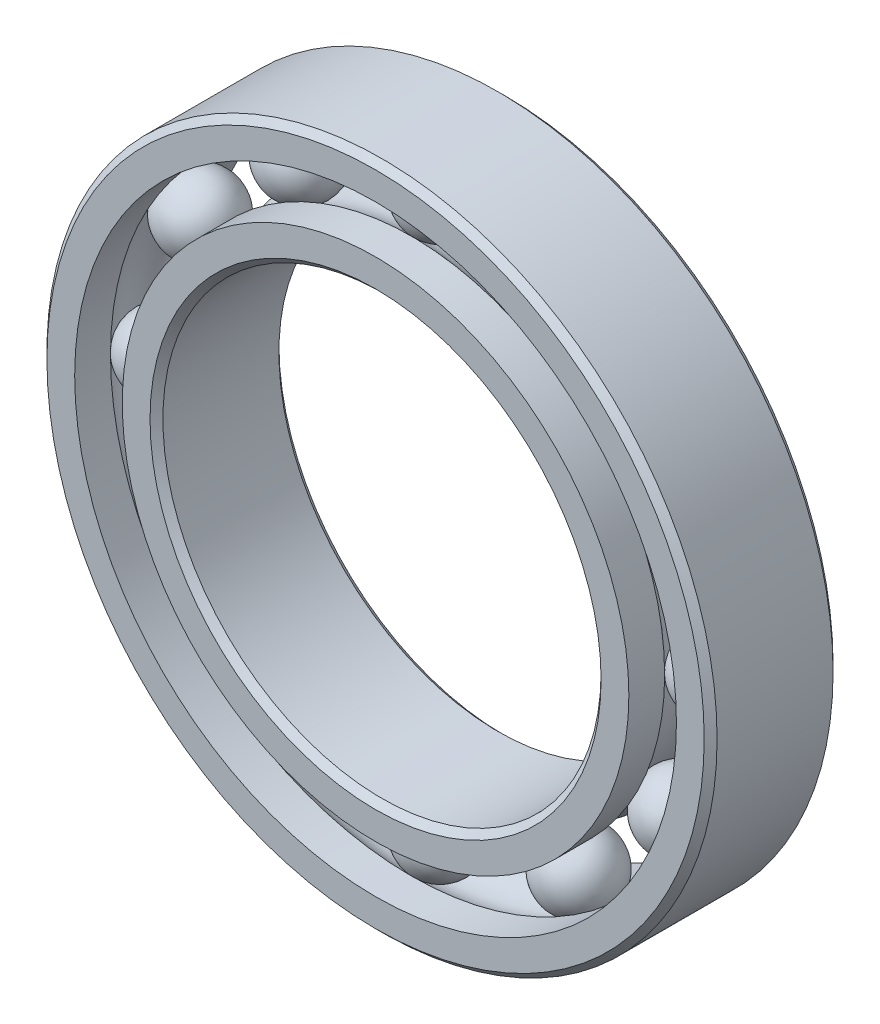
from build123d import *

# Parameters (mm, degrees)
CIRPATTERN1_COUNT = 12


with BuildPart() as part:
    # Sketch1 → Revolve1 (revolve)
    with BuildSketch(Plane(origin=(0, 0, 0), x_dir=(0, 0, -1), z_dir=(1, 0, 0))):
        with BuildLine():
            Line((2.25, 13), (-2.25, 13))
            Line((-2.25, 13), (-2.5, 12.75))
            Line((-2.5, 12.75), (-2.5, 11.673076923))
            Line((-2.5, 11.673076923), (-1.111111111, 11.673076923))
            ThreePointArc((-1.111111111, 11.673076923), (0, 12.194520303), (1.111111111, 11.673076923))
            Line((1.111111111, 11.673076923), (2.5, 11.673076923))
            Line((2.5, 11.673076923), (2.5, 12.75))
            Line((2.5, 12.75), (2.25, 13))
        make_face()
    revolve(axis=Axis((0, 0, 2.5), (0, 0, -1)))


with BuildPart() as body_2:
    # Sketch3 → Revolve3 (revolve)
    with BuildSketch(Plane(origin=(0, 0, 0), x_dir=(0, 0, -1), z_dir=(1, 0, 0))):
        with BuildLine():
            Line((-2.5, 9.826923077), (-1.111111111, 9.826923077))
            ThreePointArc((-1.111111111, 9.826923077), (0, 9.305479697), (1.111111111, 9.826923077))
            Line((1.111111111, 9.826923077), (2.5, 9.826923077))
            Line((2.5, 9.826923077), (2.5, 8.75))
            Line((2.5, 8.75), (2.25, 8.5))
            Line((2.25, 8.5), (-2.25, 8.5))
            Line((-2.25, 8.5), (-2.5, 8.75))
            Line((-2.5, 8.75), (-2.5, 9.826923077))
        make_face()
    revolve(axis=Axis((0, 0, 2.5), (0, 0, -1)))


with BuildPart() as body_3:
    # Sketch4 → Revolve4 (revolve)
    with BuildSketch(Plane(origin=(0, 0, 0), x_dir=(0, 0, -1), z_dir=(1, 0, 0))):
        with BuildLine():
            Line((-1.444520303, 10.75), (1.444520303, 10.75))
            ThreePointArc((1.444520303, 10.75), (0, 12.194520303), (-1.444520303, 10.75))
        make_face()
    revolve(axis=Axis((0, 10.75, 1.444520303), (0, 0, -1)))


with BuildPart() as cirpattern1_1:
    # CirPattern1: pattern copy
    add(body_3.part.rotate(Axis((0, 0, -2.5), (0, 0, 1)), 1 * 360 / CIRPATTERN1_COUNT))


with BuildPart() as cirpattern1_2:
    # CirPattern1: pattern copy
    add(body_3.part.rotate(Axis((0, 0, -2.5), (0, 0, 1)), 2 * 360 / CIRPATTERN1_COUNT))


with BuildPart() as cirpattern1_3:
    # CirPattern1: pattern copy
    add(body_3.part.rotate(Axis((0, 0, -2.5), (0, 0, 1)), 3 * 360 / CIRPATTERN1_COUNT))


with BuildPart() as cirpattern1_4:
    # CirPattern1: pattern copy
    add(body_3.part.rotate(Axis((0, 0, -2.5), (0, 0, 1)), 4 * 360 / CIRPATTERN1_COUNT))


with BuildPart() as cirpattern1_5:
    # CirPattern1: pattern copy
    add(body_3.part.rotate(Axis((0, 0, -2.5), (0, 0, 1)), 5 * 360 / CIRPATTERN1_COUNT))


with BuildPart() as cirpattern1_6:
    # CirPattern1: pattern copy
    add(body_3.part.rotate(Axis((0, 0, -2.5), (0, 0, 1)), 6 * 360 / CIRPATTERN1_COUNT))


with BuildPart() as cirpattern1_7:
    # CirPattern1: pattern copy
    add(body_3.part.rotate(Axis((0, 0, -2.5), (0, 0, 1)), 7 * 360 / CIRPATTERN1_COUNT))


with BuildPart() as cirpattern1_8:
    # CirPattern1: pattern copy
    add(body_3.part.rotate(Axis((0, 0, -2.5), (0, 0, 1)), 8 * 360 / CIRPATTERN1_COUNT))


with BuildPart() as cirpattern1_9:
    # CirPattern1: pattern copy
    add(body_3.part.rotate(Axis((0, 0, -2.5), (0, 0, 1)), 9 * 360 / CIRPATTERN1_COUNT))


with BuildPart() as cirpattern1_10:
    # CirPattern1: pattern copy
    add(body_3.part.rotate(Axis((0, 0, -2.5), (0, 0, 1)), 10 * 360 / CIRPATTERN1_COUNT))


with BuildPart() as cirpattern1_11:
    # CirPattern1: pattern copy
    add(body_3.part.rotate(Axis((0, 0, -2.5), (0, 0, 1)), 11 * 360 / CIRPATTERN1_COUNT))


solid = Compound([part.part, body_2.part, body_3.part, cirpattern1_1.part, cirpattern1_2.part, cirpattern1_3.part, cirpattern1_4.part, cirpattern1_5.part, cirpattern1_6.part, cirpattern1_7.part, cirpattern1_8.part, cirpattern1_9.part, cirpattern1_10.part, cirpattern1_11.part])
